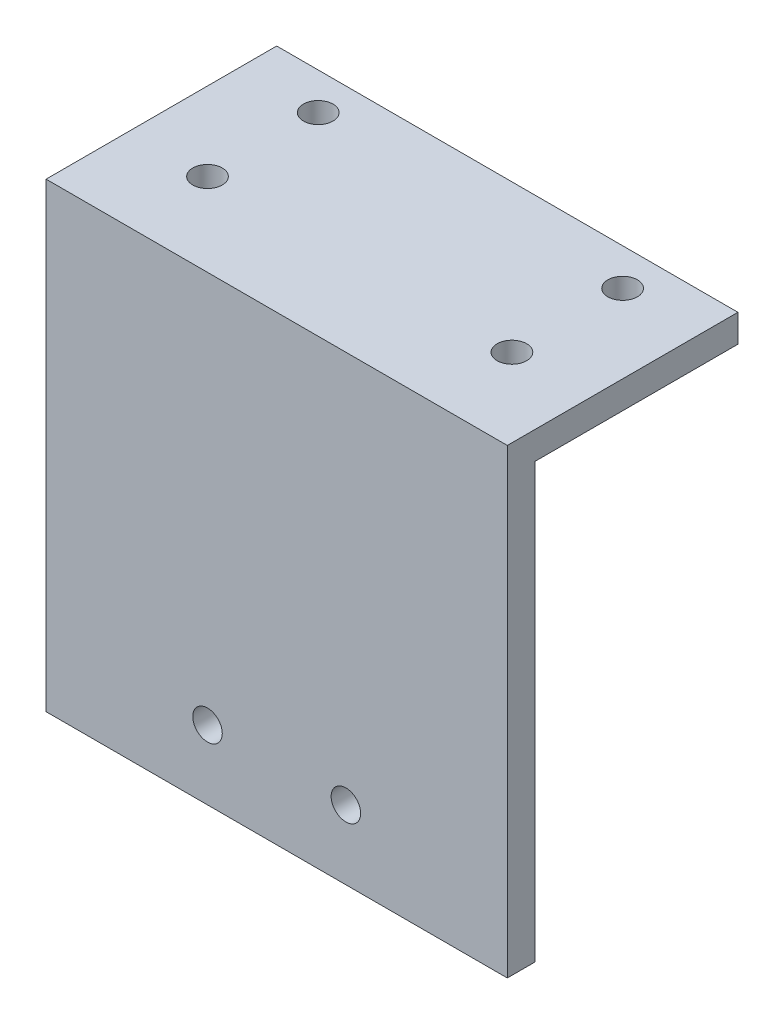
from build123d import *

# Parameters (mm, degrees)
EXTRUDE_1_DEPTH     = 50
SKETCH_2_R          = 1.6
CUT_EXTRUDE_1_DEPTH = 4
SKETCH_3_R          = 1.6
CUT_EXTRUDE_2_DEPTH = 26


with BuildPart() as part:
    # ｽｹｯﾁ1 → ﾎﾞｽ - 押し出し1 (new body)
    with BuildSketch(Plane(origin=(0, 0, 0), x_dir=(0, 0, -1), z_dir=(1, 0, 0))):
        Polygon((0, 50), (25, 50), (25, 47), (3, 47), (3, 0), (0, 0), align=None)
    extrude(amount=EXTRUDE_1_DEPTH)

    # ｽｹｯﾁ2 → ｶｯﾄ - 押し出し1 (cut, through all)
    with BuildSketch(Plane.XZ.offset(-47)):
        with Locations((8.5, -9)):
            Circle(SKETCH_2_R)
        with Locations((8.5, -21)):
            Circle(SKETCH_2_R)
        with Locations((41.5, -9)):
            Circle(SKETCH_2_R)
        with Locations((41.5, -21)):
            Circle(SKETCH_2_R)
    extrude(amount=-CUT_EXTRUDE_1_DEPTH, mode=Mode.SUBTRACT)

    # ｽｹｯﾁ3 → ｶｯﾄ - 押し出し2 (cut, through all)
    with BuildSketch(Plane.XY):
        with Locations((17.5, 7.5)):
            Circle(SKETCH_3_R)
        with Locations((32.5, 7.5)):
            Circle(SKETCH_3_R)
    extrude(amount=-CUT_EXTRUDE_2_DEPTH, mode=Mode.SUBTRACT)


solid = part.part
